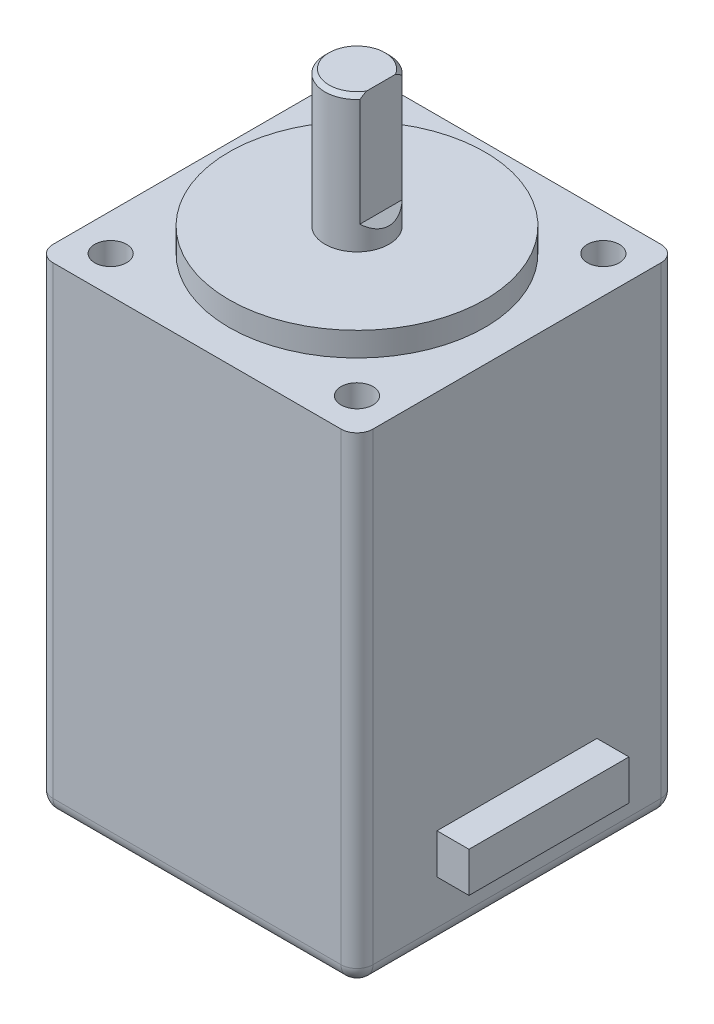
from build123d import *

# Parameters (mm, degrees)
SKETCH1_W               = 20
SKETCH1_H               = 20
BOSS_EXTRUDE1_DEPTH     = 30
SKETCH2_R               = 1
CUT_EXTRUDE1_DEPTH      = 2.5
SKETCH3_R               = 8
BOSS_EXTRUDE2_DEPTH     = 1.5
SKETCH4_R               = 2
BOSS_EXTRUDE3_DEPTH     = 10
CUT_EXTRUDE2_DEPTH      = 11
CUT_EXTRUDE2_DEPTH_BACK = 11
CHAMFER1_SIZE           = 0.25
FILLET1_R               = 1
SKETCH6_W               = 10
SKETCH6_H               = 2.5
BOSS_EXTRUDE4_DEPTH     = 12


with BuildPart() as part:
    # Sketch1 → Boss-Extrude1 (new body)
    with BuildSketch(Plane(origin=(0, 0, 0), x_dir=(1, 0, 0), z_dir=(0, 1, 0))):
        Rectangle(SKETCH1_W, SKETCH1_H)
    extrude(amount=-BOSS_EXTRUDE1_DEPTH)

    # Sketch2 → Cut-Extrude1 (cut)
    with BuildSketch(Plane(origin=(0, 0, 0), x_dir=(1, 0, 0), z_dir=(0, 1, 0))):
        with Locations((-7.7, 7.7)):
            Circle(SKETCH2_R)
        with Locations((7.7, 7.7)):
            Circle(SKETCH2_R)
        with Locations((7.7, -7.7)):
            Circle(SKETCH2_R)
        with Locations((-7.7, -7.7)):
            Circle(SKETCH2_R)
    extrude(amount=-CUT_EXTRUDE1_DEPTH, mode=Mode.SUBTRACT)

    # Sketch3 → Boss-Extrude2 (add)
    with BuildSketch(Plane(origin=(0, 0, 0), x_dir=(1, 0, 0), z_dir=(0, 1, 0))):
        Circle(SKETCH3_R)
    extrude(amount=BOSS_EXTRUDE2_DEPTH)

    # Sketch4 → Boss-Extrude3 (add)
    with BuildSketch(Plane(origin=(0, 0, 0), x_dir=(1, 0, 0), z_dir=(0, 1, 0))):
        Circle(SKETCH4_R)
    extrude(amount=BOSS_EXTRUDE3_DEPTH)

    # Sketch5 → Cut-Extrude2 (cut, two sides)
    with BuildSketch(Plane.XY) as cut_extrude2_sk:
        Polygon((2, 10), (1.5, 10), (1.5, 3), (2, 2.5), align=None)
    extrude(amount=CUT_EXTRUDE2_DEPTH, mode=Mode.SUBTRACT)
    extrude(cut_extrude2_sk.sketch, amount=-CUT_EXTRUDE2_DEPTH_BACK, mode=Mode.SUBTRACT)

    # Chamfer1
    chamfer1_edges = [part.edges().sort_by_distance(p)[0] for p in [
        (-2, 10, 0),
    ]]
    chamfer(chamfer1_edges, length=CHAMFER1_SIZE)

    # Fillet1
    fillet1_edges = [part.edges().sort_by_distance(p)[0] for p in [
        (10, -30, 0),
        (0, -30, -10),
        (-10, -30, 0),
        (0, -30, 10),
        (-10, -15, -10),
        (10, -15, -10),
        (10, -15, 10),
        (-10, -15, 10),
    ]]
    fillet(fillet1_edges, radius=FILLET1_R)

    # Sketch6 → Boss-Extrude4 (add)
    with BuildSketch(Plane(origin=(0, 0, 0), x_dir=(0, 0, -1), z_dir=(1, 0, 0))):
        with Locations((0, -25)):
            Rectangle(SKETCH6_W, SKETCH6_H)
    extrude(amount=BOSS_EXTRUDE4_DEPTH)


solid = part.part
